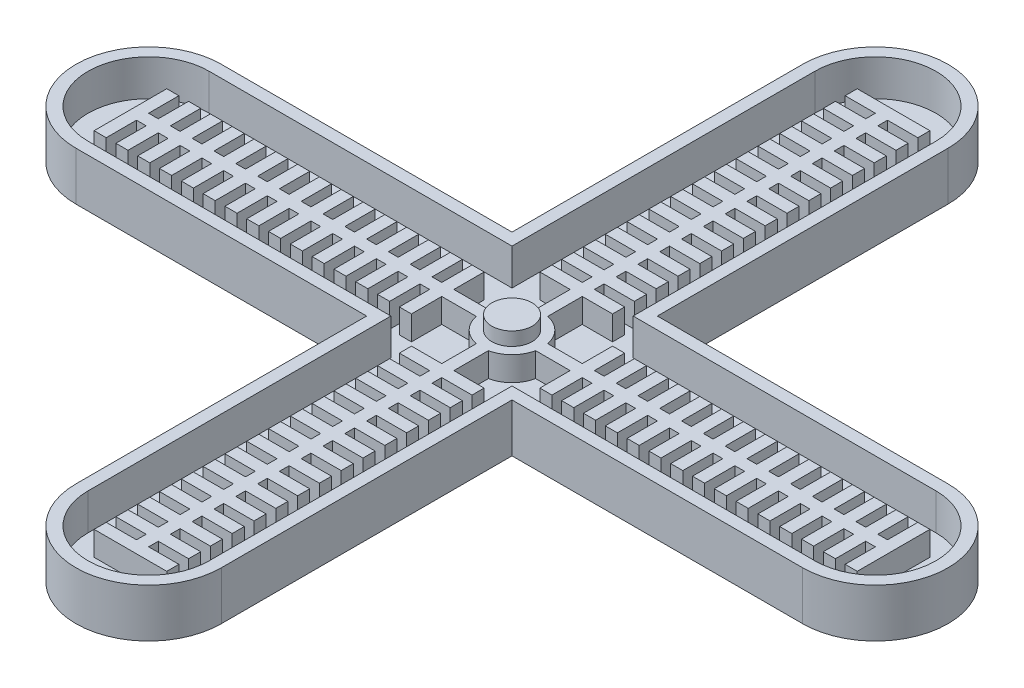
from build123d import *

# Parameters (mm, degrees)
BOSS_EXTRUDE1_DEPTH = 2.54
BOSS_EXTRUDE2_DEPTH = 5.08
BOSS_EXTRUDE4_DEPTH = 10.16
SCALE1_SCALE        = 0.9
SKETCH5_R           = 3.81
BOSS_EXTRUDE6_DEPTH = 2.54


with BuildPart() as part:
    # Sketch1 → Boss-Extrude1 (new body)
    with BuildSketch(Plane(origin=(0, 0, 0), x_dir=(1, 0, 0), z_dir=(0, 1, 0))):
        with BuildLine():
            Line((-12.7, 76.2), (-12.7, 12.7))
            Line((-12.7, 12.7), (-76.2, 12.7))
            ThreePointArc((-76.2, 12.7), (-88.9, 0), (-76.2, -12.7))
            Line((-76.2, -12.7), (-12.7, -12.7))
            Line((-12.7, -12.7), (-12.7, -76.2))
            ThreePointArc((-12.7, -76.2), (0, -88.9), (12.7, -76.2))
            Line((12.7, -76.2), (12.7, -12.7))
            Line((12.7, -12.7), (76.2, -12.7))
            ThreePointArc((76.2, -12.7), (88.9, 0), (76.2, 12.7))
            Line((76.2, 12.7), (12.7, 12.7))
            Line((12.7, 12.7), (12.7, 76.2))
            ThreePointArc((12.7, 76.2), (0, 88.9), (-12.7, 76.2))
        make_face()
    extrude(amount=BOSS_EXTRUDE1_DEPTH)

    # Sketch3 → Boss-Extrude2 (add)
    with BuildSketch(Plane(origin=(0, 2.54, 0), x_dir=(1, 0, 0), z_dir=(0, 1, 0))):
        with BuildLine():
            Line((-7.62, 80.01), (0, 80.01))
            Line((0, 80.01), (7.62, 80.01))
            Line((7.62, 80.01), (7.62, 77.47))
            Line((7.62, 77.47), (1.27, 77.47))
            Line((1.27, 77.47), (1.27, 75.438))
            Line((1.27, 75.438), (7.62, 75.438))
            Line((7.62, 75.438), (7.62, 72.898))
            Line((7.62, 72.898), (1.27, 72.898))
            Line((1.27, 72.898), (1.27, 70.866))
            Line((1.27, 70.866), (7.62, 70.866))
            Line((7.62, 70.866), (7.62, 68.326))
            Line((7.62, 68.326), (1.27, 68.326))
            Line((1.27, 68.326), (1.27, 66.294))
            Line((1.27, 66.294), (7.62, 66.294))
            Line((7.62, 66.294), (7.62, 63.754))
            Line((7.62, 63.754), (1.27, 63.754))
            Line((1.27, 63.754), (1.27, 61.722))
            Line((1.27, 61.722), (7.62, 61.722))
            Line((7.62, 61.722), (7.62, 59.182))
            Line((7.62, 59.182), (1.27, 59.182))
            Line((1.27, 59.182), (1.27, 57.15))
            Line((1.27, 57.15), (7.62, 57.15))
            Line((7.62, 57.15), (7.62, 54.61))
            Line((7.62, 54.61), (1.27, 54.61))
            Line((1.27, 54.61), (1.27, 52.578))
            Line((1.27, 52.578), (7.62, 52.578))
            Line((7.62, 52.578), (7.62, 50.038))
            Line((7.62, 50.038), (1.27, 50.038))
            Line((1.27, 50.038), (1.27, 48.006))
            Line((1.27, 48.006), (7.62, 48.006))
            Line((7.62, 48.006), (7.62, 45.466))
            Line((7.62, 45.466), (1.27, 45.466))
            Line((1.27, 45.466), (1.27, 43.434))
            Line((1.27, 43.434), (7.62, 43.434))
            Line((7.62, 43.434), (7.62, 40.894))
            Line((7.62, 40.894), (1.27, 40.894))
            Line((1.27, 40.894), (1.27, 38.862))
            Line((1.27, 38.862), (7.62, 38.862))
            Line((7.62, 38.862), (7.62, 36.322))
            Line((7.62, 36.322), (1.27, 36.322))
            Line((1.27, 36.322), (1.27, 34.29))
            Line((1.27, 34.29), (7.62, 34.29))
            Line((7.62, 34.29), (7.62, 31.75))
            Line((7.62, 31.75), (1.27, 31.75))
            Line((1.27, 31.75), (1.27, 29.718))
            Line((1.27, 29.718), (7.62, 29.718))
            Line((7.62, 29.718), (7.62, 27.178))
            Line((7.62, 27.178), (1.27, 27.178))
            Line((1.27, 27.178), (1.27, 25.146))
            Line((1.27, 25.146), (7.62, 25.146))
            Line((7.62, 25.146), (7.62, 22.606))
            Line((7.62, 22.606), (1.27, 22.606))
            Line((1.27, 22.606), (1.27, 20.574))
            Line((1.27, 20.574), (7.62, 20.574))
            Line((7.62, 20.574), (7.62, 18.034))
            Line((7.62, 18.034), (1.27, 18.034))
            Line((1.27, 18.034), (1.27, 16.002))
            Line((1.27, 16.002), (7.62, 16.002))
            Line((7.62, 16.002), (7.62, 13.462))
            Line((7.62, 13.462), (1.27, 13.462))
            Line((1.27, 13.462), (1.27, 6.221703947))
            ThreePointArc((1.27, 6.221703947), (4.490128061, 4.490128061), (6.221703947, 1.27))
            Line((6.221703947, 1.27), (13.462, 1.27))
            Line((13.462, 1.27), (13.462, 7.62))
            Line((13.462, 7.62), (16.002, 7.62))
            Line((16.002, 7.62), (16.002, 1.27))
            Line((16.002, 1.27), (18.034, 1.27))
            Line((18.034, 1.27), (18.034, 7.62))
            Line((18.034, 7.62), (20.574, 7.62))
            Line((20.574, 7.62), (20.574, 1.27))
            Line((20.574, 1.27), (22.606, 1.27))
            Line((22.606, 1.27), (22.606, 7.62))
            Line((22.606, 7.62), (25.146, 7.62))
            Line((25.146, 7.62), (25.146, 1.27))
            Line((25.146, 1.27), (27.178, 1.27))
            Line((27.178, 1.27), (27.178, 7.62))
            Line((27.178, 7.62), (29.718, 7.62))
            Line((29.718, 7.62), (29.718, 1.27))
            Line((29.718, 1.27), (31.75, 1.27))
            Line((31.75, 1.27), (31.75, 7.62))
            Line((31.75, 7.62), (34.29, 7.62))
            Line((34.29, 7.62), (34.29, 1.27))
            Line((34.29, 1.27), (36.322, 1.27))
            Line((36.322, 1.27), (36.322, 7.62))
            Line((36.322, 7.62), (38.862, 7.62))
            Line((38.862, 7.62), (38.862, 1.27))
            Line((38.862, 1.27), (40.894, 1.27))
            Line((40.894, 1.27), (40.894, 7.62))
            Line((40.894, 7.62), (43.434, 7.62))
            Line((43.434, 7.62), (43.434, 1.27))
            Line((43.434, 1.27), (45.466, 1.27))
            Line((45.466, 1.27), (45.466, 7.62))
            Line((45.466, 7.62), (48.006, 7.62))
            Line((48.006, 7.62), (48.006, 1.27))
            Line((48.006, 1.27), (50.038, 1.27))
            Line((50.038, 1.27), (50.038, 7.62))
            Line((50.038, 7.62), (52.578, 7.62))
            Line((52.578, 7.62), (52.578, 1.27))
            Line((52.578, 1.27), (54.61, 1.27))
            Line((54.61, 1.27), (54.61, 7.62))
            Line((54.61, 7.62), (57.15, 7.62))
            Line((57.15, 7.62), (57.15, 1.27))
            Line((57.15, 1.27), (59.182, 1.27))
            Line((59.182, 1.27), (59.182, 7.62))
            Line((59.182, 7.62), (61.722, 7.62))
            Line((61.722, 7.62), (61.722, 1.27))
            Line((61.722, 1.27), (63.754, 1.27))
            Line((63.754, 1.27), (63.754, 7.62))
            Line((63.754, 7.62), (66.294, 7.62))
            Line((66.294, 7.62), (66.294, 1.27))
            Line((66.294, 1.27), (68.326, 1.27))
            Line((68.326, 1.27), (68.326, 7.62))
            Line((68.326, 7.62), (70.866, 7.62))
            Line((70.866, 7.62), (70.866, 1.27))
            Line((70.866, 1.27), (72.898, 1.27))
            Line((72.898, 1.27), (72.898, 7.62))
            Line((72.898, 7.62), (75.438, 7.62))
            Line((75.438, 7.62), (75.438, 1.27))
            Line((75.438, 1.27), (77.47, 1.27))
            Line((77.47, 1.27), (77.47, 7.62))
            Line((77.47, 7.62), (80.01, 7.62))
            Line((80.01, 7.62), (80.01, 0))
            Line((80.01, 0), (80.01, -7.62))
            Line((80.01, -7.62), (77.47, -7.62))
            Line((77.47, -7.62), (77.47, -1.27))
            Line((77.47, -1.27), (75.438, -1.27))
            Line((75.438, -1.27), (75.438, -7.62))
            Line((75.438, -7.62), (72.898, -7.62))
            Line((72.898, -7.62), (72.898, -1.27))
            Line((72.898, -1.27), (70.866, -1.27))
            Line((70.866, -1.27), (70.866, -7.62))
            Line((70.866, -7.62), (68.326, -7.62))
            Line((68.326, -7.62), (68.326, -1.27))
            Line((68.326, -1.27), (66.294, -1.27))
            Line((66.294, -1.27), (66.294, -7.62))
            Line((66.294, -7.62), (63.754, -7.62))
            Line((63.754, -7.62), (63.754, -1.27))
            Line((63.754, -1.27), (61.722, -1.27))
            Line((61.722, -1.27), (61.722, -7.62))
            Line((61.722, -7.62), (59.182, -7.62))
            Line((59.182, -7.62), (59.182, -1.27))
            Line((59.182, -1.27), (57.15, -1.27))
            Line((57.15, -1.27), (57.15, -7.62))
            Line((57.15, -7.62), (54.61, -7.62))
            Line((54.61, -7.62), (54.61, -1.27))
            Line((54.61, -1.27), (52.578, -1.27))
            Line((52.578, -1.27), (52.578, -7.62))
            Line((52.578, -7.62), (50.038, -7.62))
            Line((50.038, -7.62), (50.038, -1.27))
            Line((50.038, -1.27), (48.006, -1.27))
            Line((48.006, -1.27), (48.006, -7.62))
            Line((48.006, -7.62), (45.466, -7.62))
            Line((45.466, -7.62), (45.466, -1.27))
            Line((45.466, -1.27), (43.434, -1.27))
            Line((43.434, -1.27), (43.434, -7.62))
            Line((43.434, -7.62), (40.894, -7.62))
            Line((40.894, -7.62), (40.894, -1.27))
            Line((40.894, -1.27), (38.862, -1.27))
            Line((38.862, -1.27), (38.862, -7.62))
            Line((38.862, -7.62), (36.322, -7.62))
            Line((36.322, -7.62), (36.322, -1.27))
            Line((36.322, -1.27), (34.29, -1.27))
            Line((34.29, -1.27), (34.29, -7.62))
            Line((34.29, -7.62), (31.75, -7.62))
            Line((31.75, -7.62), (31.75, -1.27))
            Line((31.75, -1.27), (29.718, -1.27))
            Line((29.718, -1.27), (29.718, -7.62))
            Line((29.718, -7.62), (27.178, -7.62))
            Line((27.178, -7.62), (27.178, -1.27))
            Line((27.178, -1.27), (25.146, -1.27))
            Line((25.146, -1.27), (25.146, -7.62))
            Line((25.146, -7.62), (22.606, -7.62))
            Line((22.606, -7.62), (22.606, -1.27))
            Line((22.606, -1.27), (20.574, -1.27))
            Line((20.574, -1.27), (20.574, -7.62))
            Line((20.574, -7.62), (18.034, -7.62))
            Line((18.034, -7.62), (18.034, -1.27))
            Line((18.034, -1.27), (16.002, -1.27))
            Line((16.002, -1.27), (16.002, -7.62))
            Line((16.002, -7.62), (13.462, -7.62))
            Line((13.462, -7.62), (13.462, -1.27))
            Line((13.462, -1.27), (6.221703947, -1.27))
            ThreePointArc((6.221703947, -1.27), (4.490128061, -4.490128061), (1.27, -6.221703947))
            Line((1.27, -6.221703947), (1.27, -13.462))
            Line((1.27, -13.462), (7.62, -13.462))
            Line((7.62, -13.462), (7.62, -16.002))
            Line((7.62, -16.002), (1.27, -16.002))
            Line((1.27, -16.002), (1.27, -18.034))
            Line((1.27, -18.034), (7.62, -18.034))
            Line((7.62, -18.034), (7.62, -20.574))
            Line((7.62, -20.574), (1.27, -20.574))
            Line((1.27, -20.574), (1.27, -22.606))
            Line((1.27, -22.606), (7.62, -22.606))
            Line((7.62, -22.606), (7.62, -25.146))
            Line((7.62, -25.146), (1.27, -25.146))
            Line((1.27, -25.146), (1.27, -27.178))
            Line((1.27, -27.178), (7.62, -27.178))
            Line((7.62, -27.178), (7.62, -29.718))
            Line((7.62, -29.718), (1.27, -29.718))
            Line((1.27, -29.718), (1.27, -31.75))
            Line((1.27, -31.75), (7.62, -31.75))
            Line((7.62, -31.75), (7.62, -34.29))
            Line((7.62, -34.29), (1.27, -34.29))
            Line((1.27, -34.29), (1.27, -36.322))
            Line((1.27, -36.322), (7.62, -36.322))
            Line((7.62, -36.322), (7.62, -38.862))
            Line((7.62, -38.862), (1.27, -38.862))
            Line((1.27, -38.862), (1.27, -40.894))
            Line((1.27, -40.894), (7.62, -40.894))
            Line((7.62, -40.894), (7.62, -43.434))
            Line((7.62, -43.434), (1.27, -43.434))
            Line((1.27, -43.434), (1.27, -45.466))
            Line((1.27, -45.466), (7.62, -45.466))
            Line((7.62, -45.466), (7.62, -48.006))
            Line((7.62, -48.006), (1.27, -48.006))
            Line((1.27, -48.006), (1.27, -50.038))
            Line((1.27, -50.038), (7.62, -50.038))
            Line((7.62, -50.038), (7.62, -52.578))
            Line((7.62, -52.578), (1.27, -52.578))
            Line((1.27, -52.578), (1.27, -54.61))
            Line((1.27, -54.61), (7.62, -54.61))
            Line((7.62, -54.61), (7.62, -57.15))
            Line((7.62, -57.15), (1.27, -57.15))
            Line((1.27, -57.15), (1.27, -59.182))
            Line((1.27, -59.182), (7.62, -59.182))
            Line((7.62, -59.182), (7.62, -61.722))
            Line((7.62, -61.722), (1.27, -61.722))
            Line((1.27, -61.722), (1.27, -63.754))
            Line((1.27, -63.754), (7.62, -63.754))
            Line((7.62, -63.754), (7.62, -66.294))
            Line((7.62, -66.294), (1.27, -66.294))
            Line((1.27, -66.294), (1.27, -68.326))
            Line((1.27, -68.326), (7.62, -68.326))
            Line((7.62, -68.326), (7.62, -70.866))
            Line((7.62, -70.866), (1.27, -70.866))
            Line((1.27, -70.866), (1.27, -72.898))
            Line((1.27, -72.898), (7.62, -72.898))
            Line((7.62, -72.898), (7.62, -75.438))
            Line((7.62, -75.438), (1.27, -75.438))
            Line((1.27, -75.438), (1.27, -77.47))
            Line((1.27, -77.47), (7.62, -77.47))
            Line((7.62, -77.47), (7.62, -80.01))
            Line((7.62, -80.01), (0, -80.01))
            Line((0, -80.01), (-7.62, -80.01))
            Line((-7.62, -80.01), (-7.62, -77.47))
            Line((-7.62, -77.47), (-1.27, -77.47))
            Line((-1.27, -77.47), (-1.27, -75.438))
            Line((-1.27, -75.438), (-7.62, -75.438))
            Line((-7.62, -75.438), (-7.62, -72.898))
            Line((-7.62, -72.898), (-1.27, -72.898))
            Line((-1.27, -72.898), (-1.27, -70.866))
            Line((-1.27, -70.866), (-7.62, -70.866))
            Line((-7.62, -70.866), (-7.62, -68.326))
            Line((-7.62, -68.326), (-1.27, -68.326))
            Line((-1.27, -68.326), (-1.27, -66.294))
            Line((-1.27, -66.294), (-7.62, -66.294))
            Line((-7.62, -66.294), (-7.62, -63.754))
            Line((-7.62, -63.754), (-1.27, -63.754))
            Line((-1.27, -63.754), (-1.27, -61.722))
            Line((-1.27, -61.722), (-7.62, -61.722))
            Line((-7.62, -61.722), (-7.62, -59.182))
            Line((-7.62, -59.182), (-1.27, -59.182))
            Line((-1.27, -59.182), (-1.27, -57.15))
            Line((-1.27, -57.15), (-7.62, -57.15))
            Line((-7.62, -57.15), (-7.62, -54.61))
            Line((-7.62, -54.61), (-1.27, -54.61))
            Line((-1.27, -54.61), (-1.27, -52.578))
            Line((-1.27, -52.578), (-7.62, -52.578))
            Line((-7.62, -52.578), (-7.62, -50.038))
            Line((-7.62, -50.038), (-1.27, -50.038))
            Line((-1.27, -50.038), (-1.27, -48.006))
            Line((-1.27, -48.006), (-7.62, -48.006))
            Line((-7.62, -48.006), (-7.62, -45.466))
            Line((-7.62, -45.466), (-1.27, -45.466))
            Line((-1.27, -45.466), (-1.27, -43.434))
            Line((-1.27, -43.434), (-7.62, -43.434))
            Line((-7.62, -43.434), (-7.62, -40.894))
            Line((-7.62, -40.894), (-1.27, -40.894))
            Line((-1.27, -40.894), (-1.27, -38.862))
            Line((-1.27, -38.862), (-7.62, -38.862))
            Line((-7.62, -38.862), (-7.62, -36.322))
            Line((-7.62, -36.322), (-1.27, -36.322))
            Line((-1.27, -36.322), (-1.27, -34.29))
            Line((-1.27, -34.29), (-7.62, -34.29))
            Line((-7.62, -34.29), (-7.62, -31.75))
            Line((-7.62, -31.75), (-1.27, -31.75))
            Line((-1.27, -31.75), (-1.27, -29.718))
            Line((-1.27, -29.718), (-7.62, -29.718))
            Line((-7.62, -29.718), (-7.62, -27.178))
            Line((-7.62, -27.178), (-1.27, -27.178))
            Line((-1.27, -27.178), (-1.27, -25.146))
            Line((-1.27, -25.146), (-7.62, -25.146))
            Line((-7.62, -25.146), (-7.62, -22.606))
            Line((-7.62, -22.606), (-1.27, -22.606))
            Line((-1.27, -22.606), (-1.27, -20.574))
            Line((-1.27, -20.574), (-7.62, -20.574))
            Line((-7.62, -20.574), (-7.62, -18.034))
            Line((-7.62, -18.034), (-1.27, -18.034))
            Line((-1.27, -18.034), (-1.27, -16.002))
            Line((-1.27, -16.002), (-7.62, -16.002))
            Line((-7.62, -16.002), (-7.62, -13.462))
            Line((-7.62, -13.462), (-1.27, -13.462))
            Line((-1.27, -13.462), (-1.27, -6.221703947))
            ThreePointArc((-1.27, -6.221703947), (-4.490128061, -4.490128061), (-6.221703947, -1.27))
            Line((-6.221703947, -1.27), (-13.462, -1.27))
            Line((-13.462, -1.27), (-13.462, -7.62))
            Line((-13.462, -7.62), (-16.002, -7.62))
            Line((-16.002, -7.62), (-16.002, -1.27))
            Line((-16.002, -1.27), (-18.034, -1.27))
            Line((-18.034, -1.27), (-18.034, -7.62))
            Line((-18.034, -7.62), (-20.574, -7.62))
            Line((-20.574, -7.62), (-20.574, -1.27))
            Line((-20.574, -1.27), (-22.606, -1.27))
            Line((-22.606, -1.27), (-22.606, -7.62))
            Line((-22.606, -7.62), (-25.146, -7.62))
            Line((-25.146, -7.62), (-25.146, -1.27))
            Line((-25.146, -1.27), (-27.178, -1.27))
            Line((-27.178, -1.27), (-27.178, -7.62))
            Line((-27.178, -7.62), (-29.718, -7.62))
            Line((-29.718, -7.62), (-29.718, -1.27))
            Line((-29.718, -1.27), (-31.75, -1.27))
            Line((-31.75, -1.27), (-31.75, -7.62))
            Line((-31.75, -7.62), (-34.29, -7.62))
            Line((-34.29, -7.62), (-34.29, -1.27))
            Line((-34.29, -1.27), (-36.322, -1.27))
            Line((-36.322, -1.27), (-36.322, -7.62))
            Line((-36.322, -7.62), (-38.862, -7.62))
            Line((-38.862, -7.62), (-38.862, -1.27))
            Line((-38.862, -1.27), (-40.894, -1.27))
            Line((-40.894, -1.27), (-40.894, -7.62))
            Line((-40.894, -7.62), (-43.434, -7.62))
            Line((-43.434, -7.62), (-43.434, -1.27))
            Line((-43.434, -1.27), (-45.466, -1.27))
            Line((-45.466, -1.27), (-45.466, -7.62))
            Line((-45.466, -7.62), (-48.006, -7.62))
            Line((-48.006, -7.62), (-48.006, -1.27))
            Line((-48.006, -1.27), (-50.038, -1.27))
            Line((-50.038, -1.27), (-50.038, -7.62))
            Line((-50.038, -7.62), (-52.578, -7.62))
            Line((-52.578, -7.62), (-52.578, -1.27))
            Line((-52.578, -1.27), (-54.61, -1.27))
            Line((-54.61, -1.27), (-54.61, -7.62))
            Line((-54.61, -7.62), (-57.15, -7.62))
            Line((-57.15, -7.62), (-57.15, -1.27))
            Line((-57.15, -1.27), (-59.182, -1.27))
            Line((-59.182, -1.27), (-59.182, -7.62))
            Line((-59.182, -7.62), (-61.722, -7.62))
            Line((-61.722, -7.62), (-61.722, -1.27))
            Line((-61.722, -1.27), (-63.754, -1.27))
            Line((-63.754, -1.27), (-63.754, -7.62))
            Line((-63.754, -7.62), (-66.294, -7.62))
            Line((-66.294, -7.62), (-66.294, -1.27))
            Line((-66.294, -1.27), (-68.326, -1.27))
            Line((-68.326, -1.27), (-68.326, -7.62))
            Line((-68.326, -7.62), (-70.866, -7.62))
            Line((-70.866, -7.62), (-70.866, -1.27))
            Line((-70.866, -1.27), (-72.898, -1.27))
            Line((-72.898, -1.27), (-72.898, -7.62))
            Line((-72.898, -7.62), (-75.438, -7.62))
            Line((-75.438, -7.62), (-75.438, -1.27))
            Line((-75.438, -1.27), (-77.47, -1.27))
            Line((-77.47, -1.27), (-77.47, -7.62))
            Line((-77.47, -7.62), (-80.01, -7.62))
            Line((-80.01, -7.62), (-80.01, 0))
            Line((-80.01, 0), (-80.01, 7.62))
            Line((-80.01, 7.62), (-77.47, 7.62))
            Line((-77.47, 7.62), (-77.47, 1.27))
            Line((-77.47, 1.27), (-75.438, 1.27))
            Line((-75.438, 1.27), (-75.438, 7.62))
            Line((-75.438, 7.62), (-72.898, 7.62))
            Line((-72.898, 7.62), (-72.898, 1.27))
            Line((-72.898, 1.27), (-70.866, 1.27))
            Line((-70.866, 1.27), (-70.866, 7.62))
            Line((-70.866, 7.62), (-68.326, 7.62))
            Line((-68.326, 7.62), (-68.326, 1.27))
            Line((-68.326, 1.27), (-66.294, 1.27))
            Line((-66.294, 1.27), (-66.294, 7.62))
            Line((-66.294, 7.62), (-63.754, 7.62))
            Line((-63.754, 7.62), (-63.754, 1.27))
            Line((-63.754, 1.27), (-61.722, 1.27))
            Line((-61.722, 1.27), (-61.722, 7.62))
            Line((-61.722, 7.62), (-59.182, 7.62))
            Line((-59.182, 7.62), (-59.182, 1.27))
            Line((-59.182, 1.27), (-57.15, 1.27))
            Line((-57.15, 1.27), (-57.15, 7.62))
            Line((-57.15, 7.62), (-54.61, 7.62))
            Line((-54.61, 7.62), (-54.61, 1.27))
            Line((-54.61, 1.27), (-52.578, 1.27))
            Line((-52.578, 1.27), (-52.578, 7.62))
            Line((-52.578, 7.62), (-50.038, 7.62))
            Line((-50.038, 7.62), (-50.038, 1.27))
            Line((-50.038, 1.27), (-48.006, 1.27))
            Line((-48.006, 1.27), (-48.006, 7.62))
            Line((-48.006, 7.62), (-45.466, 7.62))
            Line((-45.466, 7.62), (-45.466, 1.27))
            Line((-45.466, 1.27), (-43.434, 1.27))
            Line((-43.434, 1.27), (-43.434, 7.62))
            Line((-43.434, 7.62), (-40.894, 7.62))
            Line((-40.894, 7.62), (-40.894, 1.27))
            Line((-40.894, 1.27), (-38.862, 1.27))
            Line((-38.862, 1.27), (-38.862, 7.62))
            Line((-38.862, 7.62), (-36.322, 7.62))
            Line((-36.322, 7.62), (-36.322, 1.27))
            Line((-36.322, 1.27), (-34.29, 1.27))
            Line((-34.29, 1.27), (-34.29, 7.62))
            Line((-34.29, 7.62), (-31.75, 7.62))
            Line((-31.75, 7.62), (-31.75, 1.27))
            Line((-31.75, 1.27), (-29.718, 1.27))
            Line((-29.718, 1.27), (-29.718, 7.62))
            Line((-29.718, 7.62), (-27.178, 7.62))
            Line((-27.178, 7.62), (-27.178, 1.27))
            Line((-27.178, 1.27), (-25.146, 1.27))
            Line((-25.146, 1.27), (-25.146, 7.62))
            Line((-25.146, 7.62), (-22.606, 7.62))
            Line((-22.606, 7.62), (-22.606, 1.27))
            Line((-22.606, 1.27), (-20.574, 1.27))
            Line((-20.574, 1.27), (-20.574, 7.62))
            Line((-20.574, 7.62), (-18.034, 7.62))
            Line((-18.034, 7.62), (-18.034, 1.27))
            Line((-18.034, 1.27), (-16.002, 1.27))
            Line((-16.002, 1.27), (-16.002, 7.62))
            Line((-16.002, 7.62), (-13.462, 7.62))
            Line((-13.462, 7.62), (-13.462, 1.27))
            Line((-13.462, 1.27), (-6.221703947, 1.27))
            ThreePointArc((-6.221703947, 1.27), (-4.490128061, 4.490128061), (-1.27, 6.221703947))
            Line((-1.27, 6.221703947), (-1.27, 13.462))
            Line((-1.27, 13.462), (-7.62, 13.462))
            Line((-7.62, 13.462), (-7.62, 16.002))
            Line((-7.62, 16.002), (-1.27, 16.002))
            Line((-1.27, 16.002), (-1.27, 18.034))
            Line((-1.27, 18.034), (-7.62, 18.034))
            Line((-7.62, 18.034), (-7.62, 20.574))
            Line((-7.62, 20.574), (-1.27, 20.574))
            Line((-1.27, 20.574), (-1.27, 22.606))
            Line((-1.27, 22.606), (-7.62, 22.606))
            Line((-7.62, 22.606), (-7.62, 25.146))
            Line((-7.62, 25.146), (-1.27, 25.146))
            Line((-1.27, 25.146), (-1.27, 27.178))
            Line((-1.27, 27.178), (-7.62, 27.178))
            Line((-7.62, 27.178), (-7.62, 29.718))
            Line((-7.62, 29.718), (-1.27, 29.718))
            Line((-1.27, 29.718), (-1.27, 31.75))
            Line((-1.27, 31.75), (-7.62, 31.75))
            Line((-7.62, 31.75), (-7.62, 34.29))
            Line((-7.62, 34.29), (-1.27, 34.29))
            Line((-1.27, 34.29), (-1.27, 36.322))
            Line((-1.27, 36.322), (-7.62, 36.322))
            Line((-7.62, 36.322), (-7.62, 38.862))
            Line((-7.62, 38.862), (-1.27, 38.862))
            Line((-1.27, 38.862), (-1.27, 40.894))
            Line((-1.27, 40.894), (-7.62, 40.894))
            Line((-7.62, 40.894), (-7.62, 43.434))
            Line((-7.62, 43.434), (-1.27, 43.434))
            Line((-1.27, 43.434), (-1.27, 45.466))
            Line((-1.27, 45.466), (-7.62, 45.466))
            Line((-7.62, 45.466), (-7.62, 48.006))
            Line((-7.62, 48.006), (-1.27, 48.006))
            Line((-1.27, 48.006), (-1.27, 50.038))
            Line((-1.27, 50.038), (-7.62, 50.038))
            Line((-7.62, 50.038), (-7.62, 52.578))
            Line((-7.62, 52.578), (-1.27, 52.578))
            Line((-1.27, 52.578), (-1.27, 54.61))
            Line((-1.27, 54.61), (-7.62, 54.61))
            Line((-7.62, 54.61), (-7.62, 57.15))
            Line((-7.62, 57.15), (-1.27, 57.15))
            Line((-1.27, 57.15), (-1.27, 59.182))
            Line((-1.27, 59.182), (-7.62, 59.182))
            Line((-7.62, 59.182), (-7.62, 61.722))
            Line((-7.62, 61.722), (-1.27, 61.722))
            Line((-1.27, 61.722), (-1.27, 63.754))
            Line((-1.27, 63.754), (-7.62, 63.754))
            Line((-7.62, 63.754), (-7.62, 66.294))
            Line((-7.62, 66.294), (-1.27, 66.294))
            Line((-1.27, 66.294), (-1.27, 68.326))
            Line((-1.27, 68.326), (-7.62, 68.326))
            Line((-7.62, 68.326), (-7.62, 70.866))
            Line((-7.62, 70.866), (-1.27, 70.866))
            Line((-1.27, 70.866), (-1.27, 72.898))
            Line((-1.27, 72.898), (-7.62, 72.898))
            Line((-7.62, 72.898), (-7.62, 75.438))
            Line((-7.62, 75.438), (-1.27, 75.438))
            Line((-1.27, 75.438), (-1.27, 77.47))
            Line((-1.27, 77.47), (-7.62, 77.47))
            Line((-7.62, 77.47), (-7.62, 80.01))
        make_face()
    extrude(amount=BOSS_EXTRUDE2_DEPTH)

    # Sketch4 → Boss-Extrude4 (add)
    with BuildSketch(Plane(origin=(0, 0, 0), x_dir=(1, 0, 0), z_dir=(0, 1, 0))):
        with BuildLine():
            ThreePointArc((0, -91.44), (-10.776307345, -86.976307345), (-15.24, -76.2))
            Line((-15.24, -76.2), (-15.24, -15.24))
            Line((-15.24, -15.24), (-76.2, -15.24))
            ThreePointArc((-76.2, -15.24), (-86.976307345, -10.776307345), (-91.44, 0))
            ThreePointArc((-91.44, 0), (-86.976307345, 10.776307345), (-76.2, 15.24))
            Line((-76.2, 15.24), (-15.24, 15.24))
            Line((-15.24, 15.24), (-15.24, 76.2))
            ThreePointArc((-15.24, 76.2), (-10.776307345, 86.976307345), (0, 91.44))
            ThreePointArc((0, 91.44), (10.776307345, 86.976307345), (15.24, 76.2))
            Line((15.24, 76.2), (15.24, 15.24))
            Line((15.24, 15.24), (76.2, 15.24))
            ThreePointArc((76.2, 15.24), (86.976307345, 10.776307345), (91.44, 0))
            ThreePointArc((91.44, 0), (86.976307345, -10.776307345), (76.2, -15.24))
            Line((76.2, -15.24), (15.24, -15.24))
            Line((15.24, -15.24), (15.24, -76.2))
            ThreePointArc((15.24, -76.2), (10.776307345, -86.976307345), (0, -91.44))
        make_face()
        with BuildLine():
            ThreePointArc((-12.7, -76.2), (-8.980256121, -85.180256121), (0, -88.9))
            ThreePointArc((0, -88.9), (8.980256121, -85.180256121), (12.7, -76.2))
            Line((12.7, -76.2), (12.7, -12.7))
            Line((12.7, -12.7), (76.2, -12.7))
            ThreePointArc((76.2, -12.7), (85.180256121, -8.980256121), (88.9, 0))
            ThreePointArc((88.9, 0), (85.180256121, 8.980256121), (76.2, 12.7))
            Line((76.2, 12.7), (12.7, 12.7))
            Line((12.7, 12.7), (12.7, 76.2))
            ThreePointArc((12.7, 76.2), (8.980256121, 85.180256121), (0, 88.9))
            ThreePointArc((0, 88.9), (-8.980256121, 85.180256121), (-12.7, 76.2))
            Line((-12.7, 76.2), (-12.7, 12.7))
            Line((-12.7, 12.7), (-76.2, 12.7))
            ThreePointArc((-76.2, 12.7), (-85.180256121, 8.980256121), (-88.9, 0))
            ThreePointArc((-88.9, 0), (-85.180256121, -8.980256121), (-76.2, -12.7))
            Line((-76.2, -12.7), (-12.7, -12.7))
            Line((-12.7, -12.7), (-12.7, -76.2))
        make_face(mode=Mode.SUBTRACT)
    extrude(amount=BOSS_EXTRUDE4_DEPTH)


with BuildPart() as part_1:
    # Scale1: scaled about (0, 0, 0)
    add(part.part.scale(SCALE1_SCALE))

    # Sketch5 → Boss-Extrude6 (add)
    with BuildSketch(Plane(origin=(0, 6.858, 0), x_dir=(1, 0, 0), z_dir=(0, 1, 0))):
        Circle(SKETCH5_R)
    extrude(amount=BOSS_EXTRUDE6_DEPTH)


solid = part_1.part
